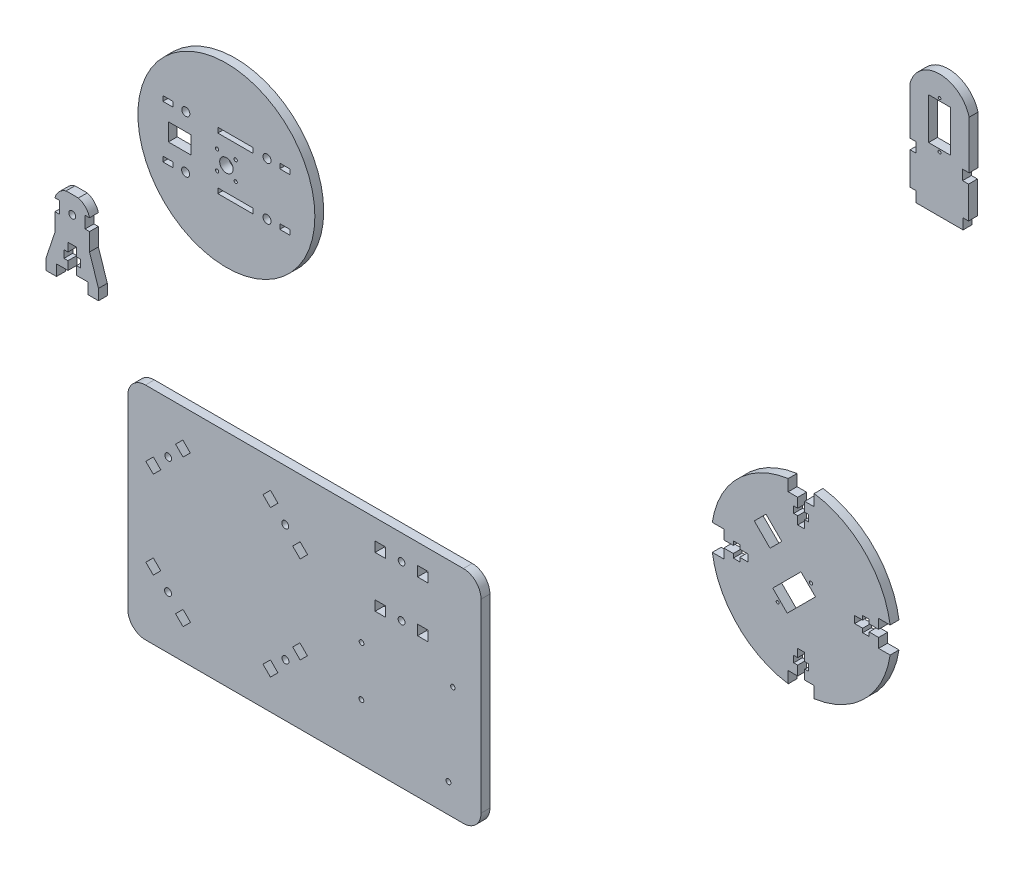
from build123d import *

# Parameters (mm, degrees)
SKETCH2_R           = 1.927682149
SKETCH2_R_2         = 1.965447869
SKETCH2_R_3         = 1.892615742
SKETCH2_R_4         = 1.931502603
SKETCH2_R_5         = 1.328987324
SKETCH2_R_6         = 1.256139718
SKETCH2_R_7         = 1.955
SKETCH2_R_8         = 1.947832563
SKETCH2_R_9         = 1.346221639
SKETCH2_R_10        = 1.388588177
SKETCH2_W           = 5.927
SKETCH2_H           = 5.645543841
SKETCH2_H_2         = 5.614229543
SKETCH2_H_3         = 5.725940204
SKETCH2_H_4         = 5.592813932
BOSS_EXTRUDE3_DEPTH = 5
SKETCH2_4_R         = 1.955
BOSS_EXTRUDE4_DEPTH = 5
SKETCH3_R           = 0.835052083
SKETCH3_R_2         = 0.921054197
BOSS_EXTRUDE5_DEPTH = 5
SKETCH3_3_R         = 0.748566325
SKETCH3_3_R_2       = 0.861949717
SKETCH3_3_W         = 12.418
SKETCH3_3_H         = 23.425
BOSS_EXTRUDE6_DEPTH = 5
SKETCH3_4_R         = 50
SKETCH3_4_R_2       = 3.785
SKETCH3_4_R_3       = 0.925
SKETCH3_4_R_4       = 2.272019255
SKETCH3_4_R_5       = 2.271176345
SKETCH3_4_R_6       = 2.271427424
SKETCH3_4_R_7       = 2.277279876
SKETCH3_4_W         = 5.6445
SKETCH3_4_H         = 2.821176605
SKETCH3_4_W_2       = 12.7001
SKETCH3_4_H_2       = 9.9
SKETCH3_4_H_3       = 2.843268376
SKETCH3_4_W_3       = 19.771671323
SKETCH3_4_H_4       = 2.8223
SKETCH3_4_W_4       = 19.7559
SKETCH3_4_H_5       = 2.855959838
SKETCH3_4_H_6       = 2.794761023
SKETCH3_4_H_7       = 2.819580997
BOSS_EXTRUDE7_DEPTH = 5


with BuildPart() as part:
    # Sketch2 → Boss-Extrude3 (new body)
    with BuildSketch(Plane.XY):
        with BuildLine():
            Line((189.603, -27.931368938), (10, -27.931368938))
            ThreePointArc((10, -27.931368938), (2.928932188, -30.860301126), (0, -37.931368938))
            Line((0, -37.931368938), (0, -142.659400732))
            ThreePointArc((0, -142.659400732), (2.928932188, -149.730468544), (10, -152.659400732))
            Line((10, -152.659400732), (189.603, -152.659400732))
            ThreePointArc((189.603, -152.659400732), (196.674067812, -149.730468544), (199.603, -142.659400732))
            Line((199.603, -142.659400732), (199.603, -37.931368938))
            ThreePointArc((199.603, -37.931368938), (196.674067812, -30.860301126), (189.603, -27.931368938))
        make_face()
        with Locations((22.839397497, -56.730535518)):
            Circle(SKETCH2_R, mode=Mode.SUBTRACT)
        with Locations((88.963812598, -56.794889022)):
            Circle(SKETCH2_R_2, mode=Mode.SUBTRACT)
        with Locations((154.694647781, -42.076845181)):
            Circle(SKETCH2_R_3, mode=Mode.SUBTRACT)
        with Locations((154.690357003, -70.942028449)):
            Circle(SKETCH2_R_4, mode=Mode.SUBTRACT)
        with Locations((132.088269085, -92.914994072)):
            Circle(SKETCH2_R_5, mode=Mode.SUBTRACT)
        with Locations((183.675750412, -88.886548904)):
            Circle(SKETCH2_R_6, mode=Mode.SUBTRACT)
        with Locations((22.757067444, -122.885983842)):
            Circle(SKETCH2_R_7, mode=Mode.SUBTRACT)
        with Locations((89.089219983, -122.853718773)):
            Circle(SKETCH2_R_8, mode=Mode.SUBTRACT)
        with Locations((132.018162412, -120.868386552)):
            Circle(SKETCH2_R_9, mode=Mode.SUBTRACT)
        with Locations((181.221290164, -136.408039981)):
            Circle(SKETCH2_R_10, mode=Mode.SUBTRACT)
        Polygon((10.200294259, -65.171368938), (14.433294259, -69.377368938), (18.666697533, -65.116789752), (14.433697533, -60.910789752), align=None, mode=Mode.SUBTRACT)
        Polygon((27.020294259, -48.378368938), (31.226294259, -52.611368938), (35.330585238, -48.533256995), (31.124585238, -44.300256995), align=None, mode=Mode.SUBTRACT)
        Polygon((76.382294259, -48.378368938), (80.615294259, -52.611368938), (84.856236991, -48.370426206), (80.623236991, -44.137426206), align=None, mode=Mode.SUBTRACT)
        Polygon((93.173294259, -65.171368938), (97.406294259, -69.377368938), (101.611336803, -65.145332541), (97.378336803, -60.939332541), align=None, mode=Mode.SUBTRACT)
        with Locations((166.691794259, -42.169597018)):
            Rectangle(SKETCH2_W, SKETCH2_H, mode=Mode.SUBTRACT)
        with Locations((142.703794259, -42.185254167)):
            Rectangle(SKETCH2_W, SKETCH2_H_2, mode=Mode.SUBTRACT)
        with Locations((166.691794259, -70.915398836)):
            Rectangle(SKETCH2_W, SKETCH2_H_3, mode=Mode.SUBTRACT)
        with Locations((142.703794259, -70.981961972)):
            Rectangle(SKETCH2_W, SKETCH2_H_4, mode=Mode.SUBTRACT)
        Polygon((10.200294259, -114.560168938), (14.433294259, -118.766268938), (18.639034985, -114.533630511), (14.406034985, -110.327530511), align=None, mode=Mode.SUBTRACT)
        Polygon((26.993294259, -131.353168938), (31.226294256, -135.586568935), (35.457852449, -131.355410568), (31.224852453, -127.122010571), align=None, mode=Mode.SUBTRACT)
        Polygon((76.382294259, -131.353168938), (80.615294259, -135.586568938), (84.847770554, -131.354492556), (80.614770554, -127.121092556), align=None, mode=Mode.SUBTRACT)
        Polygon((93.173294259, -114.560168938), (97.406294259, -118.793568938), (101.496148694, -114.70410094), (97.263148694, -110.47070094), align=None, mode=Mode.SUBTRACT)
    extrude(amount=BOSS_EXTRUDE3_DEPTH)


with BuildPart() as body_2:
    # Sketch2_4 → Boss-Extrude4 (new body)
    with BuildSketch(Plane.XY):
        with BuildLine():
            Line((-46.205346306, 6.069), (-46.205346306, 0))
            Line((-46.205346306, 0), (-40.278346306, 0))
            Line((-40.278346306, 0), (-40.278346306, 6.209))
            Line((-40.278346306, 6.209), (-33.788346306, 6.209))
            Line((-33.788346306, 6.209), (-33.788346306, 11.008))
            Line((-33.788346306, 11.008), (-36.045346306, 11.008))
            Line((-36.045346306, 11.008), (-36.045346306, 15.241))
            Line((-36.045346306, 15.241), (-33.787346306, 15.241))
            Line((-33.787346306, 15.241), (-33.787346306, 20.018965401))
            Line((-33.787346306, 20.018965401), (-31.375346306, 20.018965401))
            Line((-31.375346306, 20.018965401), (-28.963346306, 20.018965401))
            Line((-28.963346306, 20.018965401), (-28.963346306, 15.241))
            Line((-28.963346306, 15.241), (-26.705346306, 15.241))
            Line((-26.705346306, 15.241), (-26.705346306, 11.008))
            Line((-26.705346306, 11.008), (-28.962346306, 11.008))
            Line((-28.962346306, 11.008), (-28.962346306, 6.209))
            Line((-28.962346306, 6.209), (-22.472346306, 6.209))
            Line((-22.472346306, 6.209), (-22.472346306, 0))
            Line((-22.472346306, 0), (-16.545346306, 0))
            Line((-16.545346306, 0), (-16.545346306, 6.069))
            Line((-16.545346306, 6.069), (-21.625346306, 21.309))
            Line((-21.625346306, 21.309), (-21.625346306, 31.309))
            Line((-21.625346306, 31.309), (-24.165346306, 31.309))
            Line((-24.165346306, 31.309), (-24.165346306, 38.082))
            Line((-24.165346306, 38.082), (-21.625346306, 38.082))
            ThreePointArc((-21.625346306, 38.082), (-23.900792185, 42.177151256), (-27.90009545, 44.61712895))
            Line((-27.90009545, 44.61712895), (-31.366233796, 44.61712895))
            Line((-31.366233796, 44.61712895), (-31.384458817, 44.61712895))
            Line((-31.384458817, 44.61712895), (-34.850597163, 44.61712895))
            ThreePointArc((-34.850597163, 44.61712895), (-38.849900428, 42.177151256), (-41.125346306, 38.082))
            Line((-41.125346306, 38.082), (-38.585346306, 38.082))
            Line((-38.585346306, 38.082), (-38.585346306, 31.309))
            Line((-38.585346306, 31.309), (-41.125346306, 31.309))
            Line((-41.125346306, 31.309), (-41.125346306, 21.309))
            Line((-41.125346306, 21.309), (-46.205346306, 6.069))
        make_face()
        with Locations((-31.375346306, 34.658965401)):
            Circle(SKETCH2_4_R, mode=Mode.SUBTRACT)
    extrude(amount=BOSS_EXTRUDE4_DEPTH)


with BuildPart() as body_3:
    # Sketch3 → Boss-Extrude5 (new body)
    with BuildSketch(Plane.XY.offset(5)):
        with BuildLine():
            Line((378.178, 12.418), (378.178, 18.9092))
            Line((378.178, 18.9092), (383.54, 18.9092))
            Line((383.54, 18.9092), (383.54, 24.2715))
            Line((383.54, 24.2715), (381.282, 24.2715))
            Line((381.282, 24.2715), (381.282, 27.9395))
            Line((381.282, 27.9395), (383.54, 27.9395))
            Line((383.54, 27.9395), (383.54, 32.4561))
            Line((383.54, 32.4561), (387.491, 32.4561))
            Line((387.491, 32.4561), (387.491, 27.9395))
            Line((387.491, 27.9395), (389.749, 27.9395))
            Line((389.749, 27.9395), (389.749, 24.2715))
            Line((389.749, 24.2715), (387.491, 24.2715))
            Line((387.491, 24.2715), (387.491, 18.9092))
            Line((387.491, 18.9092), (392.853, 18.9092))
            Line((392.853, 18.9092), (392.853, 12.418))
            ThreePointArc((392.853, 12.418), (421.413979559, 26.754562579), (435.751, 55.3154))
            Line((435.751, 55.3154), (429.26, 55.3154))
            Line((429.26, 55.3154), (429.26, 60.6777))
            Line((429.26, 60.6777), (423.898, 60.6777))
            Line((423.898, 60.6777), (423.898, 58.4209))
            Line((423.898, 58.4209), (420.229, 58.4209))
            Line((420.229, 58.4209), (420.229, 60.6777))
            Line((420.229, 60.6777), (415.713, 60.6777))
            Line((415.713, 60.6777), (415.713, 64.6289))
            Line((415.713, 64.6289), (420.229, 64.6289))
            Line((420.229, 64.6289), (420.229, 66.8877))
            Line((420.229, 66.8877), (423.898, 66.8877))
            Line((423.898, 66.8877), (423.898, 64.6289))
            Line((423.898, 64.6289), (429.26, 64.6289))
            Line((429.26, 64.6289), (429.26, 69.9902))
            Line((429.26, 69.9902), (435.751, 69.9902))
            ThreePointArc((435.751, 69.9902), (421.414492246, 98.551959609), (392.853, 112.889))
            Line((392.853, 112.889), (392.853, 106.398))
            Line((392.853, 106.398), (387.491, 106.398))
            Line((387.491, 106.398), (387.491, 101.035))
            Line((387.491, 101.035), (389.749, 101.035))
            Line((389.749, 101.035), (389.749, 97.3672))
            Line((389.749, 97.3672), (387.491, 97.3672))
            Line((387.491, 97.3672), (387.491, 92.8506))
            Line((387.491, 92.8506), (383.54, 92.8506))
            Line((383.54, 92.8506), (383.54, 97.3672))
            Line((383.54, 97.3672), (381.282, 97.3672))
            Line((381.282, 97.3672), (381.282, 101.035))
            Line((381.282, 101.035), (383.54, 101.035))
            Line((383.54, 101.035), (383.54, 106.398))
            Line((383.54, 106.398), (378.178, 106.398))
            Line((378.178, 106.398), (378.178, 112.889034877))
            ThreePointArc((378.178, 112.889034877), (349.61635429, 98.552044927), (335.279, 69.9902))
            Line((335.279, 69.9902), (341.771, 69.9902))
            Line((341.771, 69.9902), (341.771, 64.6289))
            Line((341.771, 64.6289), (347.133, 64.6289))
            Line((347.133, 64.6289), (347.133, 66.8877))
            Line((347.133, 66.8877), (350.802, 66.8877))
            Line((350.802, 66.8877), (350.802, 64.6289))
            Line((350.802, 64.6289), (355.318, 64.6289))
            Line((355.318, 64.6289), (355.318, 60.6777))
            Line((355.318, 60.6777), (350.802, 60.6777))
            Line((350.802, 60.6777), (350.802, 58.4209))
            Line((350.802, 58.4209), (347.133, 58.4209))
            Line((347.133, 58.4209), (347.133, 60.6777))
            Line((347.133, 60.6777), (341.771, 60.6777))
            Line((341.771, 60.6777), (341.771, 55.3154))
            Line((341.771, 55.3154), (335.279, 55.3154))
            ThreePointArc((335.279, 55.3154), (349.616866979, 26.754477262), (378.178, 12.418))
        make_face()
        with Locations((372.196607298, 49.38965)):
            Circle(SKETCH3_R, mode=Mode.SUBTRACT)
        with Locations((391.034474624, 68.203451775)):
            Circle(SKETCH3_R_2, mode=Mode.SUBTRACT)
        Polygon((369.429, 54.8926), (385.374, 70.8379), (393.549233469, 62.662820342), (377.604233469, 46.717520342), align=None, mode=Mode.SUBTRACT)
        Polygon((358.987, 82.5498), (365.619, 89.1826), (374.525064609, 80.277609576), (367.893064609, 73.644809576), align=None, mode=Mode.SUBTRACT)
    extrude(amount=BOSS_EXTRUDE5_DEPTH)


with BuildPart() as body_4:
    # Sketch3_3 → Boss-Extrude6 (new body)
    with BuildSketch(Plane.XY.offset(5)):
        with BuildLine():
            Line((480.399, 313.553201161), (480.399, 340.802414281))
            ThreePointArc((480.399, 340.802414281), (463.7055, 353.603420022), (447.012, 340.802414281))
            Line((447.012, 340.802414281), (447.012, 313.832))
            Line((447.012, 313.832), (450.427, 313.832))
            Line((450.427, 313.832), (450.427, 308.187))
            Line((450.427, 308.187), (447.04, 308.187))
            Line((447.04, 308.187), (447.04, 289.843))
            Line((447.04, 289.843), (450.427, 289.843))
            Line((450.427, 289.843), (450.427, 283.916))
            Line((450.427, 283.916), (476.956, 283.916))
            Line((476.956, 283.916), (476.956, 289.843))
            Line((476.956, 289.843), (480.07269328, 289.843))
            Line((480.07269328, 289.843), (480.07269328, 307.908201161))
            Line((480.07269328, 307.908201161), (476.68669328, 307.908201161))
            Line((476.68669328, 307.908201161), (476.68669328, 313.553201161))
            Line((476.68669328, 313.553201161), (480.399, 313.553201161))
        make_face()
        with Locations((463.657037934, 341.805828962)):
            Circle(SKETCH3_3_R, mode=Mode.SUBTRACT)
        with Locations((463.640100147, 315.348445535)):
            Circle(SKETCH3_3_R_2, mode=Mode.SUBTRACT)
        with Locations((463.691, 328.6475)):
            Rectangle(SKETCH3_3_W, SKETCH3_3_H, mode=Mode.SUBTRACT)
    extrude(amount=BOSS_EXTRUDE6_DEPTH)


with BuildPart() as body_5:
    # Sketch3_4 → Boss-Extrude7 (new body)
    with BuildSketch(Plane.XY.offset(5)):
        with Locations((60.71181161, 107.410494733)):
            Circle(SKETCH3_4_R)
        with Locations((60.71181161, 107.410494733)):
            Circle(SKETCH3_4_R_2, mode=Mode.SUBTRACT)
        with Locations((65.96181161, 102.060494733)):
            Circle(SKETCH3_4_R_3, mode=Mode.SUBTRACT)
        with Locations((37.788019692, 122.202009735)):
            Circle(SKETCH3_4_R_4, mode=Mode.SUBTRACT)
        with Locations((37.675128381, 92.578417091)):
            Circle(SKETCH3_4_R_5, mode=Mode.SUBTRACT)
        with Locations((83.679301434, 122.21103434)):
            Circle(SKETCH3_4_R_6, mode=Mode.SUBTRACT)
        with Locations((83.685941388, 92.571394262)):
            Circle(SKETCH3_4_R_7, mode=Mode.SUBTRACT)
        with Locations((55.46181161, 102.060494733)):
            Circle(SKETCH3_4_R_3, mode=Mode.SUBTRACT)
        with Locations((65.96181161, 112.760494733)):
            Circle(SKETCH3_4_R_3, mode=Mode.SUBTRACT)
        with Locations((55.46181161, 112.760494733)):
            Circle(SKETCH3_4_R_3, mode=Mode.SUBTRACT)
        with Locations((27.65725, 122.202411698)):
            Rectangle(SKETCH3_4_W, SKETCH3_4_H, mode=Mode.SUBTRACT)
        with Locations((34.28955, 107.410494733)):
            Rectangle(SKETCH3_4_W_2, SKETCH3_4_H_2, mode=Mode.SUBTRACT)
        with Locations((27.65725, 92.578834188)):
            Rectangle(SKETCH3_4_W, SKETCH3_4_H_3, mode=Mode.SUBTRACT)
        with Locations((65.764735661, 92.56835)):
            Rectangle(SKETCH3_4_W_3, SKETCH3_4_H_4, mode=Mode.SUBTRACT)
        with Locations((65.75685, 122.217979919)):
            Rectangle(SKETCH3_4_W_4, SKETCH3_4_H_5, mode=Mode.SUBTRACT)
        with Locations((93.69825, 122.187380512)):
            Rectangle(SKETCH3_4_W, SKETCH3_4_H_6, mode=Mode.SUBTRACT)
        with Locations((93.69825, 92.566990499)):
            Rectangle(SKETCH3_4_W, SKETCH3_4_H_7, mode=Mode.SUBTRACT)
    extrude(amount=BOSS_EXTRUDE7_DEPTH)


solid = Compound([part.part, body_2.part, body_3.part, body_4.part, body_5.part])
